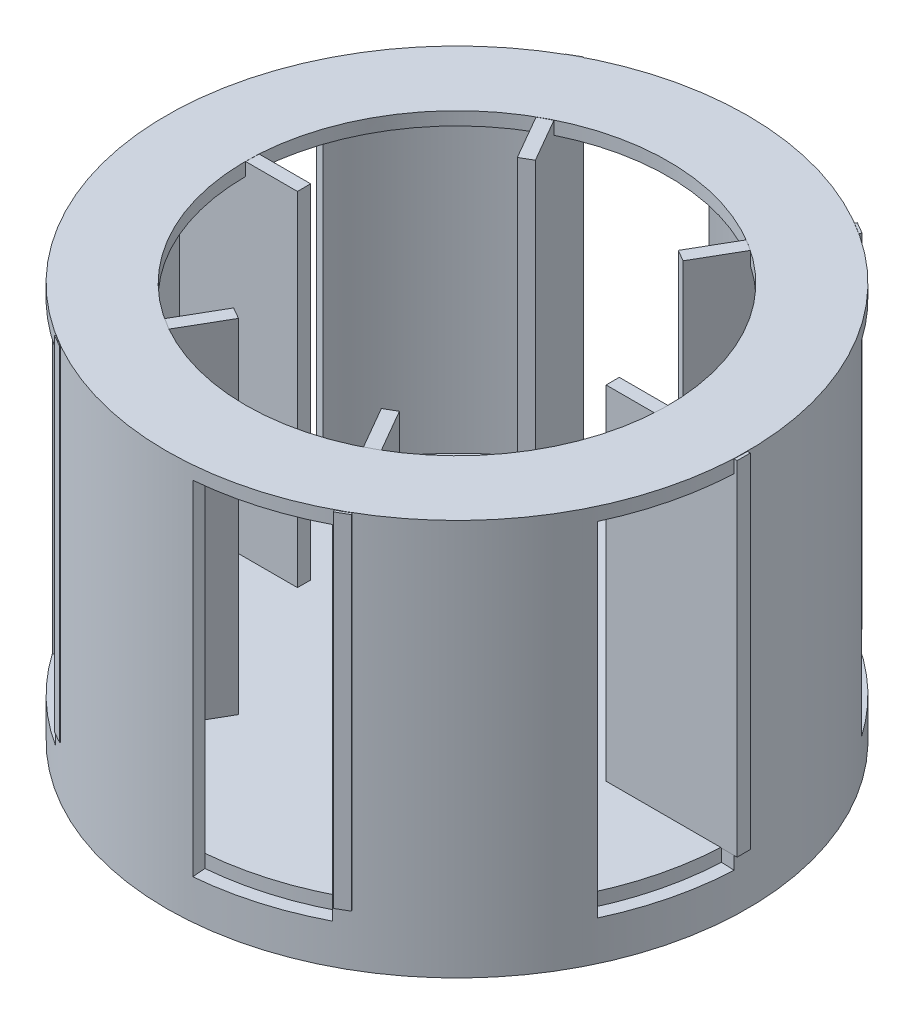
from build123d import *

# Parameters (mm, degrees)
SKETCH1_W                 = 5.5
SKETCH1_H                 = 7
SHELL1_T                  = -0.25
SHELL1_THICKNESS_2_FACE_R = 5.25
SHELL1_THICKNESS_2_DEPTH  = 0.25
SKETCH6_R                 = 5.5
SKETCH6_R_2               = 4
BOSS_EXTRUDE1_DEPTH       = 0.25
WRAP1_SECTION_W           = 0.25
WRAP1_SECTION_H           = 6.5
WRAP1_ANGLE               = 22.397441082
CIRPATTERN1_COUNT         = 6
SKETCH10_W                = 2.48
SKETCH10_H                = 6.5
BOSS_EXTRUDE2_DEPTH       = 0.25
CIRPATTERN2_COUNT         = 6
CUT_EXTRUDE1_REACH        = 14.692
SKETCH12_R                = 0.75


with BuildPart() as part:
    # Sketch1 → Revolve1 (revolve)
    with BuildSketch(Plane.XY, mode=Mode.PRIVATE) as revolve1_sk:
        with Locations((2.75, 3.5)):
            Rectangle(SKETCH1_W, SKETCH1_H)
    revolve(revolve1_sk.sketch.rotate(Axis((0, 0, 0), (0, 1, 0)), 90), axis=Axis((0, 0, 0), (0, 1, 0)))

    # Shell1
    shell1_openings = [part.faces().sort_by_distance(p)[0] for p in [
        (0, 7, 0),
    ]]
    offset(amount=SHELL1_T, openings=shell1_openings, kind=Kind.INTERSECTION)

    # Shell1 thickness 2 face (on inner face of the shell) → Shell1 thickness 2 (add)
    with BuildSketch(Plane(origin=(0, 0.25, 0), x_dir=(0, 0, -1), z_dir=(0, -1, 0))):
        Circle(SHELL1_THICKNESS_2_FACE_R)
    extrude(amount=-SHELL1_THICKNESS_2_DEPTH)

    # Sketch6 → Boss-Extrude1 (add)
    with BuildSketch(Plane(origin=(0, 7, 0), x_dir=(1, 0, 0), z_dir=(0, 1, 0))):
        with Locations(Location((0, 0, 0), (0, 0, 90))):
            Circle(SKETCH6_R)
        with Locations(Location((0, 0, 0), (0, 0, 270))):
            Circle(SKETCH6_R_2, mode=Mode.SUBTRACT)
    extrude(amount=-BOSS_EXTRUDE1_DEPTH)

    # Wrap1 section (on wrap section) → Wrap1 (revolve, cut)
    with BuildSketch(Plane(origin=(0, 0, 0), x_dir=(0.9062945487659477, 0, 0.42264665014303293), z_dir=(-0.42264665014303293, 0, 0.9062945487659477))):
        with Locations((5.375, 3.5)):
            Rectangle(WRAP1_SECTION_W, WRAP1_SECTION_H)
    wrap1 = revolve(axis=Axis((0, 0, 0), (0, 1, 0)), revolution_arc=WRAP1_ANGLE, mode=Mode.SUBTRACT)

    # CirPattern1: Wrap1 ×6 about axis
    cirpattern1_axis = Axis((0, 0, 0), (0, 1, 0))
    for i in range(1, CIRPATTERN1_COUNT):
        add(wrap1.rotate(cirpattern1_axis, i * 360 / CIRPATTERN1_COUNT), mode=Mode.SUBTRACT)

    # Sketch10 → Boss-Extrude2 (add)
    with BuildSketch(Plane.XY):
        with Locations((-4.26, 3.745038645)):
            Rectangle(SKETCH10_W, SKETCH10_H)
    boss_extrude2 = extrude(amount=-BOSS_EXTRUDE2_DEPTH)

    # CirPattern2: Boss-Extrude2 ×6 about axis
    cirpattern2_axis = Axis((0.026764782, 0, 0.000808926), (0, 1, 0))
    for i in range(1, CIRPATTERN2_COUNT):
        add(boss_extrude2.rotate(cirpattern2_axis, i * 360 / CIRPATTERN2_COUNT))

    # Sketch11 → Revolve3 (revolve)
    with BuildSketch(Plane.XY, mode=Mode.PRIVATE) as revolve3_sk:
        Polygon((-5.5, 0), (0, 0), (0, -3), (-1.5, -3), (-1.5, -0.5), (-5.5, -0.5), align=None)
    revolve(revolve3_sk.sketch.rotate(Axis((0, -3, 0), (0, 1, 0)), 270), axis=Axis((0, -3, 0), (0, 1, 0)))

    # Sketch12 → Cut-Extrude1 (cut, up to next)
    with BuildSketch(Plane.XZ.offset(3), mode=Mode.PRIVATE) as cut_extrude1_sk1:
        with Locations(Location((0, 0, 0), (0, 0, 270))):
            Circle(SKETCH12_R)
    cut_extrude1_tool1 = extrude(cut_extrude1_sk1.sketch, amount=-CUT_EXTRUDE1_REACH, mode=Mode.PRIVATE) & part.part
    add(cut_extrude1_tool1.solids().sort_by_distance((0, -3, 0))[0], mode=Mode.SUBTRACT)


solid = part.part
